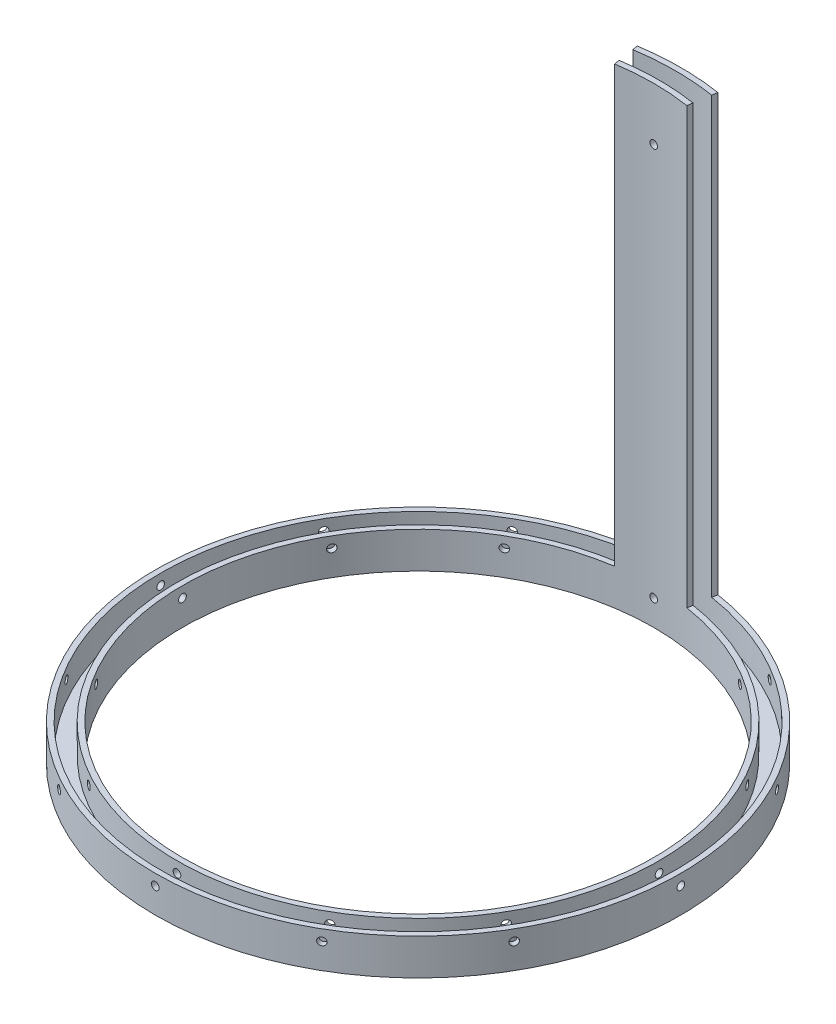
from build123d import *

# Parameters (mm, degrees)
SKETCH1_R               = 92.075
SKETCH1_R_2             = 82.55
BOSS_EXTRUDE1_DEPTH     = 12.7
CUT_EXTRUDE2_START      = -92.075
SKETCH3_R               = 1.35255
CUT_EXTRUDE2_DEPTH      = 9.536081
CIRPATTERN1_COUNT       = 12
BOSS_EXTRUDE2_DEPTH     = 152.4
LPATTERN1_COUNT         = 2
LPATTERN1_PITCH         = 137.668
SKETCH2_R               = 90.17
SKETCH2_R_2             = 84.455
CUT_EXTRUDE1_DEPTH      = 152.4
CUT_EXTRUDE1_DEPTH_BACK = 10.16


with BuildPart() as part:
    # Sketch1 → Boss-Extrude1 (new body)
    with BuildSketch(Plane(origin=(0, 0, 0), x_dir=(1, 0, 0), z_dir=(0, 1, 0))):
        Circle(SKETCH1_R)
        Circle(SKETCH1_R_2, mode=Mode.SUBTRACT)
    extrude(amount=BOSS_EXTRUDE1_DEPTH)

    # Sketch3 → Cut-Extrude2 (cut)
    with BuildSketch(Plane.XY.offset(CUT_EXTRUDE2_START)):
        with Locations((0, 8.89)):
            Circle(SKETCH3_R)
    cut_extrude2 = extrude(amount=CUT_EXTRUDE2_DEPTH, mode=Mode.SUBTRACT)

    # CirPattern1: Cut-Extrude2 ×12 about axis
    cirpattern1_axis = Axis((0, 12.7, 0), (0, 1, 0))
    for i in range(1, CIRPATTERN1_COUNT):
        add(cut_extrude2.rotate(cirpattern1_axis, i * 360 / CIRPATTERN1_COUNT), mode=Mode.SUBTRACT)

    # Sketch4 → Boss-Extrude2 (add)
    with BuildSketch(Plane(origin=(0, 12.7, 0), x_dir=(1, 0, 0), z_dir=(0, 1, 0))):
        with BuildLine():
            Line((-12.7, 81.567226875), (-14.165384615, 90.978829975))
            ThreePointArc((-14.165384615, 90.978829975), (-0.056482912, 92.074982675), (14.053753031, 90.996140856))
            Line((14.053753031, 90.996140856), (12.599916511, 81.582746975))
            ThreePointArc((12.599916511, 81.582746975), (-0.050639852, 82.549984468), (-12.7, 81.567226875))
        make_face()
    extrude(amount=BOSS_EXTRUDE2_DEPTH)

    # LPattern1: Cut-Extrude2 ×2
    with Locations(*[(0, i * LPATTERN1_PITCH, 0) for i in range(1, LPATTERN1_COUNT)]):
        add(cut_extrude2, mode=Mode.SUBTRACT)

    # Sketch2 → Cut-Extrude1 (cut, two sides)
    with BuildSketch(Plane(origin=(0, 12.7, 0), x_dir=(1, 0, 0), z_dir=(0, 1, 0))) as cut_extrude1_sk:
        Circle(SKETCH2_R)
        Circle(SKETCH2_R_2, mode=Mode.SUBTRACT)
    extrude(amount=CUT_EXTRUDE1_DEPTH, mode=Mode.SUBTRACT)
    extrude(cut_extrude1_sk.sketch, amount=-CUT_EXTRUDE1_DEPTH_BACK, mode=Mode.SUBTRACT)


solid = part.part
